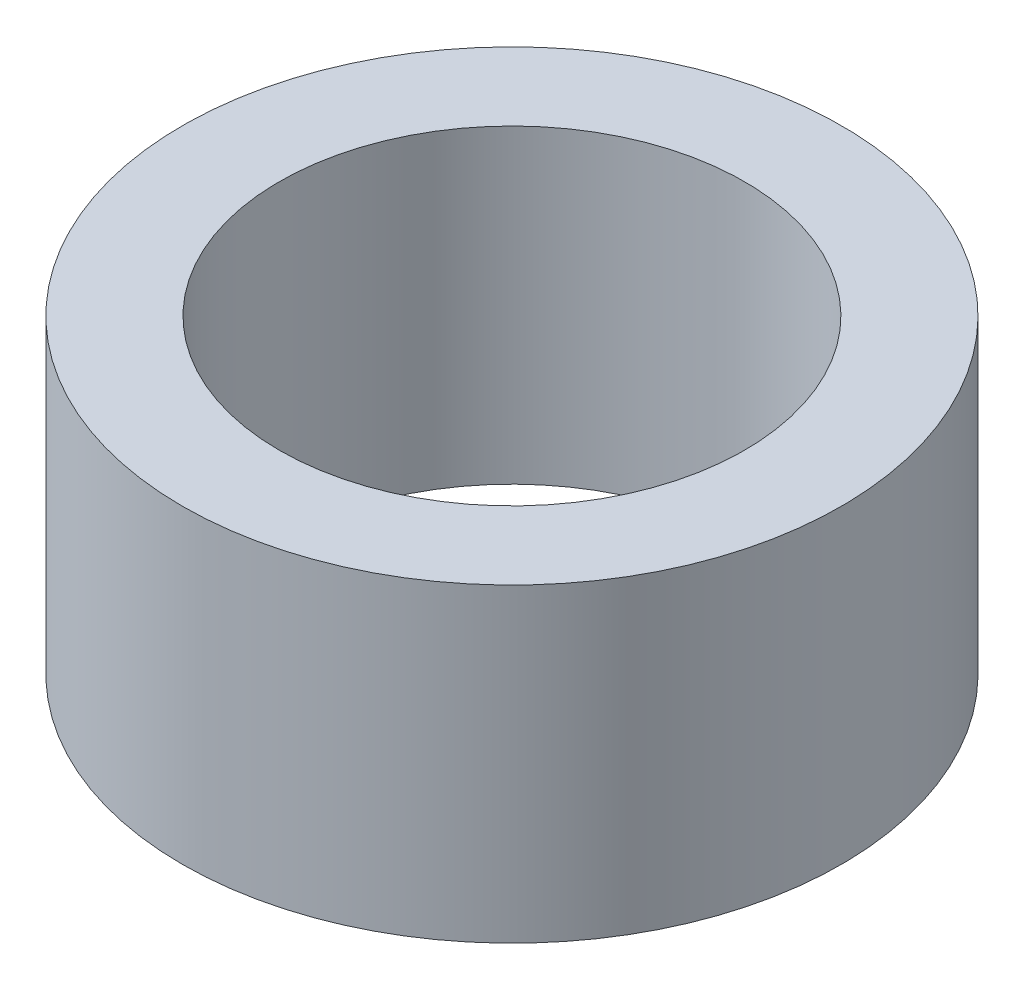
from build123d import *

# Parameters (mm, degrees)
SKETCH1_R           = 42.5
SKETCH1_R_2         = 30
BOSS_EXTRUDE1_DEPTH = 40


with BuildPart() as part:
    # Sketch1 → Boss-Extrude1 (new body)
    with BuildSketch(Plane(origin=(0, 0, 0), x_dir=(1, 0, 0), z_dir=(0, 1, 0))):
        Circle(SKETCH1_R)
        Circle(SKETCH1_R_2, mode=Mode.SUBTRACT)
    extrude(amount=BOSS_EXTRUDE1_DEPTH)


solid = part.part
